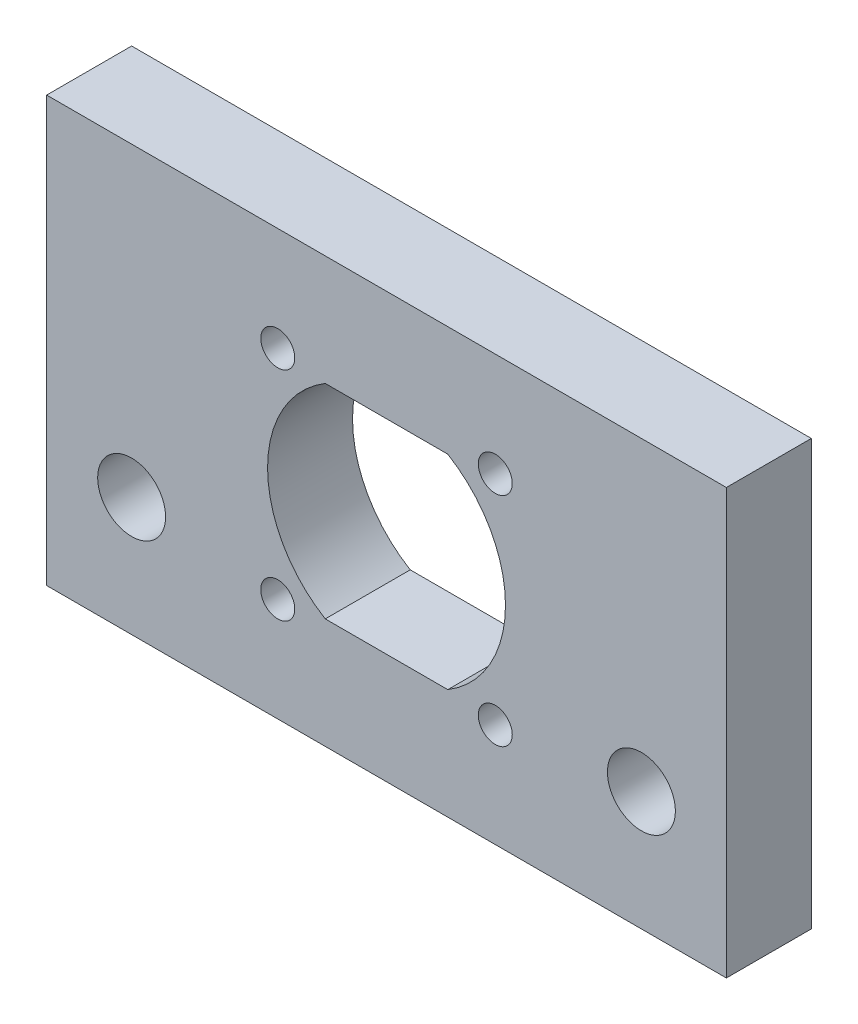
from build123d import *

# Parameters (mm, degrees)
SKETCH1_W           = 40
SKETCH1_H           = 25
SKETCH1_R           = 2
SKETCH1_R_2         = 1
BOSS_EXTRUDE1_DEPTH = 5


with BuildPart() as part:
    # Sketch1 → Boss-Extrude1 (new body)
    with BuildSketch(Plane.XY):
        Rectangle(SKETCH1_W, SKETCH1_H)
        with Locations((15, -5.5)):
            Circle(SKETCH1_R, mode=Mode.SUBTRACT)
        with Locations((-6.4, 6.4)):
            Circle(SKETCH1_R_2, mode=Mode.SUBTRACT)
        with Locations((-15, -5.5)):
            Circle(SKETCH1_R, mode=Mode.SUBTRACT)
        with Locations((6.4, 6.4)):
            Circle(SKETCH1_R_2, mode=Mode.SUBTRACT)
        with Locations((6.4, -6.4)):
            Circle(SKETCH1_R_2, mode=Mode.SUBTRACT)
        with Locations((-6.4, -6.4)):
            Circle(SKETCH1_R_2, mode=Mode.SUBTRACT)
        with BuildLine():
            Line((-3.605551275, 6), (3.605551275, 6))
            ThreePointArc((3.605551275, 6), (7, 0), (3.605551275, -6))
            Line((3.605551275, -6), (-3.605551275, -6))
            ThreePointArc((-3.605551275, -6), (-7, 0), (-3.605551275, 6))
        make_face(mode=Mode.SUBTRACT)
    extrude(amount=BOSS_EXTRUDE1_DEPTH)


solid = part.part
